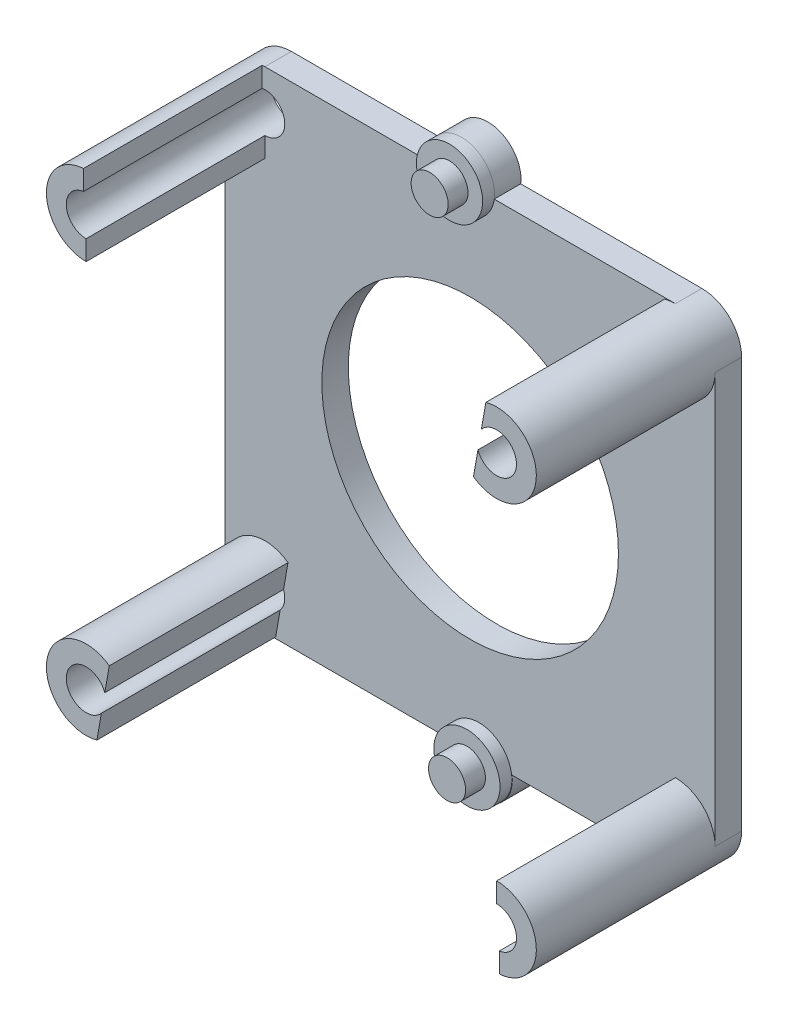
from build123d import *

# Parameters (mm, degrees)
SKETCH1_R      = 1.5
SKETCH1_R_2    = 11.2
EXTRUDE1_DEPTH = 2
SKETCH2_R      = 2.5
EXTRUDE2_DEPTH = 0.9
SKETCH3_R      = 1.4
EXTRUDE3_DEPTH = 1.5
EXTRUDE4_DEPTH = 13.5
EXTRUDE5_DEPTH = 13.5
SKETCH6_W      = 0.2
SKETCH6_H      = 4.339086574
EXTRUDE6_DEPTH = 13.5


with BuildPart() as part:
    # Sketch1 → Extrude1 (new body)
    with BuildSketch(Plane.XY):
        with BuildLine():
            Line((-18.5, 15.5), (-18.5, -15.5))
            ThreePointArc((-18.5, -15.5), (-17.621320344, -17.621320344), (-15.5, -18.5))
            Line((-15.5, -18.5), (-1.853762559, -18.5))
            ThreePointArc((-1.853762559, -18.5), (0.656979507, -21.34366179), (3.167721572, -18.5))
            Line((3.167721572, -18.5), (15.5, -18.5))
            ThreePointArc((15.5, -18.5), (17.621320344, -17.621320344), (18.5, -15.5))
            Line((18.5, -15.5), (18.5, 15.5))
            ThreePointArc((18.5, 15.5), (17.621320344, 17.621320344), (15.5, 18.5))
            Line((15.5, 18.5), (1.819299557, 18.5))
            ThreePointArc((1.819299557, 18.5), (-0.656979507, 21.309467878), (-3.13325857, 18.5))
            Line((-3.13325857, 18.5), (-15.5, 18.5))
            ThreePointArc((-15.5, 18.5), (-17.621320344, 17.621320344), (-18.5, 15.5))
        make_face()
        with Locations((15.5, 15.5)):
            Circle(SKETCH1_R, mode=Mode.SUBTRACT)
        with Locations((-15.5, 15.5)):
            Circle(SKETCH1_R, mode=Mode.SUBTRACT)
        Circle(SKETCH1_R_2, mode=Mode.SUBTRACT)
        with Locations((15.5, -15.5)):
            Circle(SKETCH1_R, mode=Mode.SUBTRACT)
        with Locations((-15.5, -15.5)):
            Circle(SKETCH1_R, mode=Mode.SUBTRACT)
    extrude(amount=EXTRUDE1_DEPTH)

    # Sketch2 → Extrude2 (add)
    with BuildSketch(Plane.XY.offset(2)):
        with Locations(Location((-0.656979507, 18.813431552, 0), (0, 0, 187.202274666))):
            Circle(SKETCH2_R)
        with Locations(Location((0.656979507, -18.813431552, 0), (0, 0, 180))):
            Circle(SKETCH2_R)
    extrude(amount=EXTRUDE2_DEPTH)

    # Sketch3 → Extrude3 (add)
    with BuildSketch(Plane.XY.offset(2.9)):
        with Locations((-0.656979507, 18.813431552)):
            Circle(SKETCH3_R)
        with Locations((0.656979507, -18.813431552)):
            Circle(SKETCH3_R)
    extrude(amount=EXTRUDE3_DEPTH)

    # Sketch4 → Extrude4 (add)
    with BuildSketch(Plane.XY.offset(2)):
        with BuildLine():
            Line((15.5, -14), (15.5, -12.5))
            ThreePointArc((15.5, -12.5), (18.5, -15.5), (15.5, -18.5))
            Line((15.5, -18.5), (15.5, -17))
            ThreePointArc((15.5, -17), (17, -15.5), (15.5, -14))
        make_face()
        with BuildLine():
            Line((-14.897310813, -12.561162518), (-15.198655407, -14.030581259))
            ThreePointArc((-15.198655407, -14.030581259), (-16.969418741, -15.198655407), (-15.801344593, -16.969418741))
            Line((-15.801344593, -16.969418741), (-16.102689187, -18.438837482))
            ThreePointArc((-16.102689187, -18.438837482), (-18.438837482, -14.897310813), (-14.897310813, -12.561162518))
        make_face()
        with BuildLine():
            Line((-15.5, 17), (-15.5, 18.5))
            ThreePointArc((-15.5, 18.5), (-18.5, 15.5), (-15.5, 12.5))
            Line((-15.5, 12.5), (-15.5, 14))
            ThreePointArc((-15.5, 14), (-17, 15.5), (-15.5, 17))
        make_face()
        with BuildLine():
            Line((16.102689187, 18.438837482), (15.801344593, 16.969418741))
            ThreePointArc((15.801344593, 16.969418741), (16.969418741, 15.198655407), (15.198655407, 14.030581259))
            Line((15.198655407, 14.030581259), (14.897310813, 12.561162518))
            ThreePointArc((14.897310813, 12.561162518), (18.438837482, 14.897310813), (16.102689187, 18.438837482))
        make_face()
    extrude(amount=EXTRUDE4_DEPTH)

    # Sketch5 → Extrude5 (add)
    with BuildSketch(Plane.XY.offset(15.5)):
        with BuildLine():
            Line((14.684749395, 18.387103471), (14.348199746, 16.460914239))
            ThreePointArc((14.348199746, 16.460914239), (16.977615135, 15.241826583), (14.090600687, 14.98658635))
            Line((14.090600687, 14.98658635), (13.754051037, 13.060397118))
            ThreePointArc((13.754051037, 13.060397118), (18.45523027, 14.983653166), (14.684749395, 18.387103471))
        make_face()
        with BuildLine():
            Line((-13.754051037, -13.060397118), (-14.090600687, -14.98658635))
            ThreePointArc((-14.090600687, -14.98658635), (-16.977615135, -15.241826583), (-14.348199746, -16.460914239))
            Line((-14.348199746, -16.460914239), (-14.684749395, -18.387103471))
            ThreePointArc((-14.684749395, -18.387103471), (-18.45523027, -14.983653166), (-13.754051037, -13.060397118))
        make_face()
    extrude(amount=-EXTRUDE5_DEPTH)

    # Sketch6 → Extrude6 (cut)
    with BuildSketch(Plane.XY.offset(15.5)):
        Polygon((-15.5, 19.617766956), (-15.5, 15.861892736), (-15.7, 15.875), (-15.7, 19.617766956), align=None)
        with Locations((15.6, -18.094430424)):
            Rectangle(SKETCH6_W, SKETCH6_H)
    extrude(amount=-EXTRUDE6_DEPTH, mode=Mode.SUBTRACT)


solid = part.part
